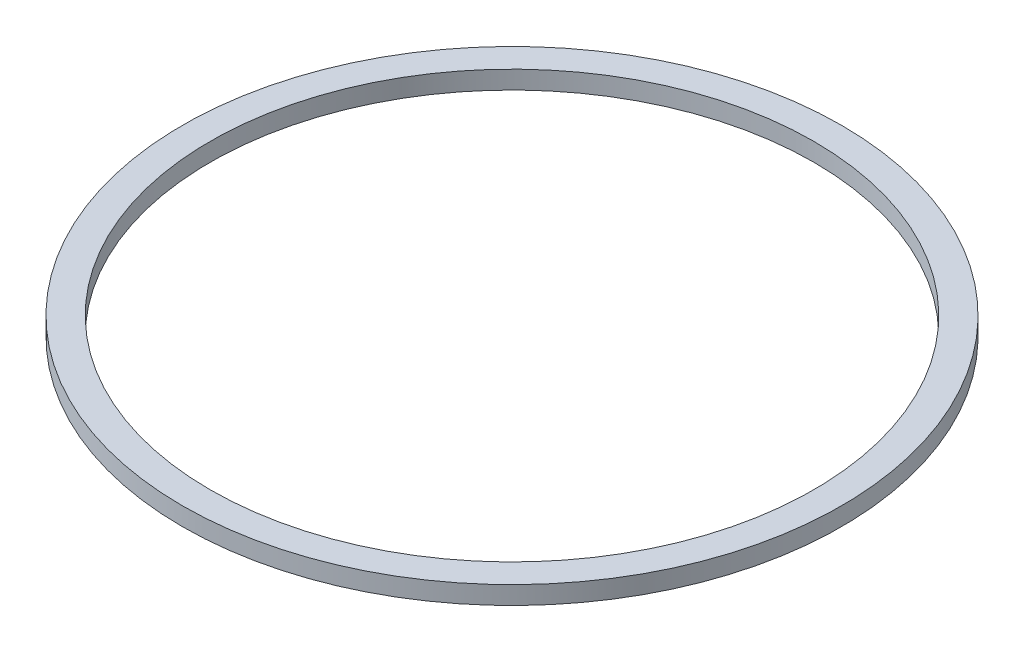
from build123d import *

# Parameters (mm, degrees)
SKETCH1_R           = 27.3
SKETCH1_R_2         = 25
BOSS_EXTRUDE1_DEPTH = 1.5


with BuildPart() as part:
    # Sketch1 → Boss-Extrude1 (new body)
    with BuildSketch(Plane(origin=(0, 0, 0), x_dir=(1, 0, 0), z_dir=(0, 1, 0))):
        Circle(SKETCH1_R)
        Circle(SKETCH1_R_2, mode=Mode.SUBTRACT)
    extrude(amount=BOSS_EXTRUDE1_DEPTH)


solid = part.part
